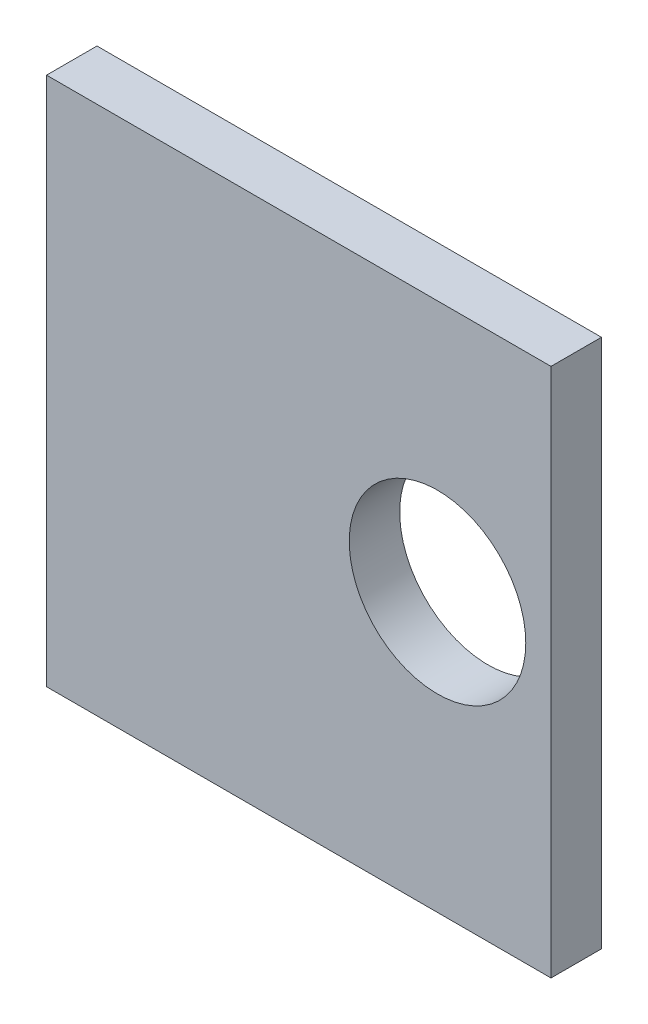
from build123d import *

# Parameters (mm, degrees)
SKETCH1_W           = 63.5
SKETCH1_H           = 66.675
SKETCH1_R           = 11.1125
BOSS_EXTRUDE1_DEPTH = 6.35


with BuildPart() as part:
    # Sketch1 → Boss-Extrude1 (new body)
    with BuildSketch(Plane.XY):
        with Locations((-17.4625, -1.5875)):
            Rectangle(SKETCH1_W, SKETCH1_H)
        Circle(SKETCH1_R, mode=Mode.SUBTRACT)
    extrude(amount=BOSS_EXTRUDE1_DEPTH)


solid = part.part
